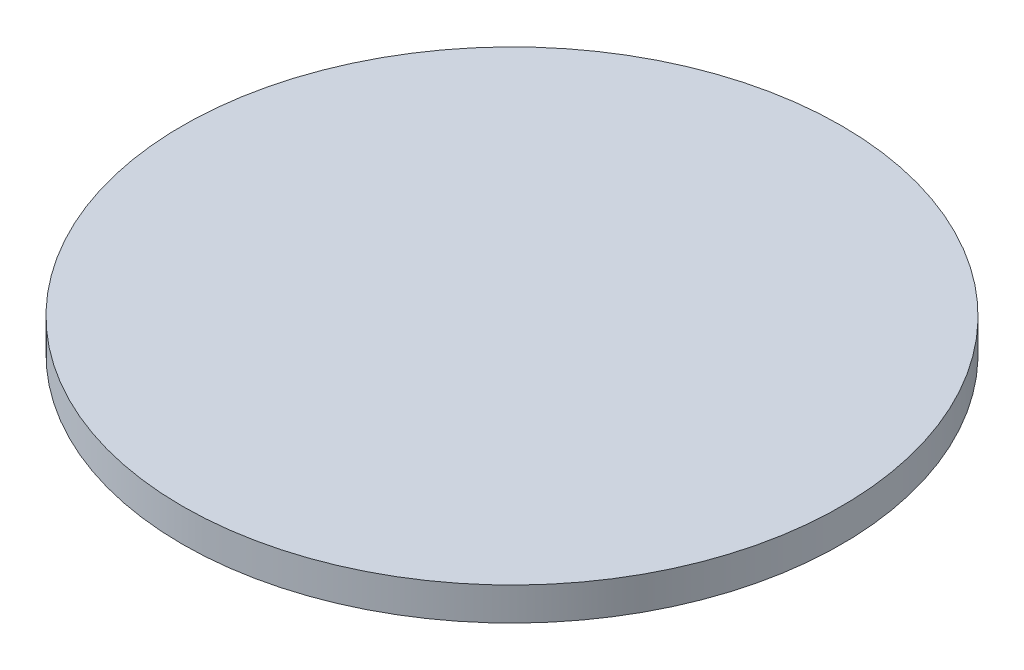
from build123d import *

# Parameters (mm, degrees)
SKETCH_1_R      = 12.5
EXTRUDE_1_DEPTH = 1.25


with BuildPart() as part:
    # 草图1 → 凸台-拉伸1 (new body)
    with BuildSketch(Plane(origin=(0, 0, 0), x_dir=(1, 0, 0), z_dir=(0, 1, 0))):
        with Locations(Location((0, 0, 0), (0, 0, 270))):  # turned: the seam where the file's is
            Circle(SKETCH_1_R)
    extrude(amount=EXTRUDE_1_DEPTH)


solid = part.part
